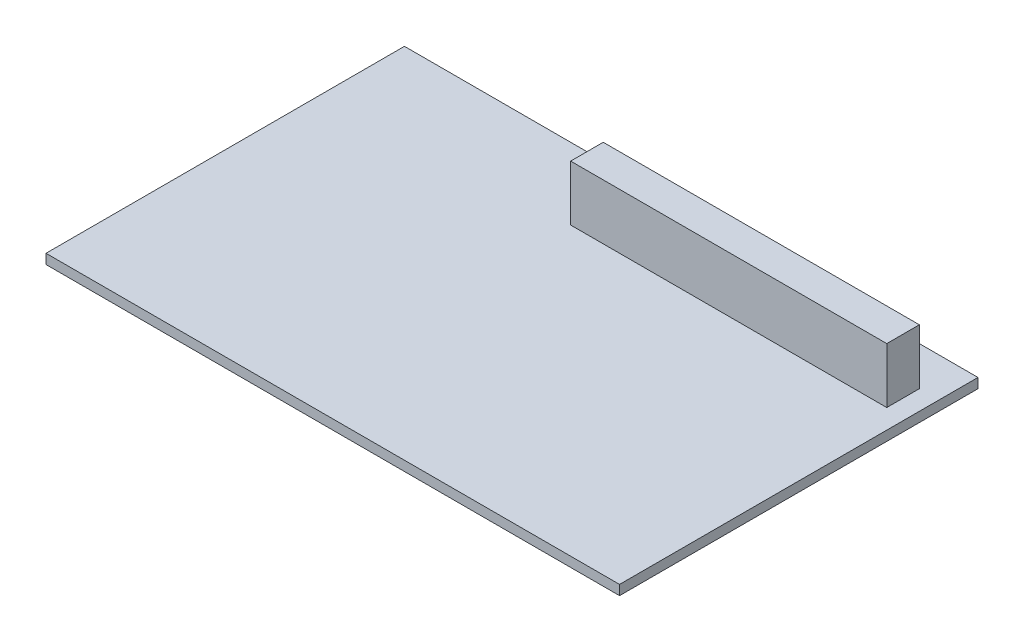
from build123d import *

# Parameters (mm, degrees)
SZKIC1_W                    = 88
SZKIC1_H                    = 55
DODANIE_WYCI_GNI_CIE1_DEPTH = 1.5
SZKIC2_W                    = 48.5
SZKIC2_H                    = 5
DODANIE_WYCI_GNI_CIE2_DEPTH = 8.5


with BuildPart() as part:
    # Szkic1 → Dodanie-wyciągnięcie1 (new body)
    with BuildSketch(Plane(origin=(0, 0, 0), x_dir=(1, 0, 0), z_dir=(0, 1, 0))):
        Rectangle(SZKIC1_W, SZKIC1_H)
    extrude(amount=DODANIE_WYCI_GNI_CIE1_DEPTH)

    # Szkic2 → Dodanie-wyciągnięcie2 (add)
    with BuildSketch(Plane(origin=(0, 1.5, 0), x_dir=(1, 0, 0), z_dir=(0, 1, 0))):
        with Locations((16.75, 19)):
            Rectangle(SZKIC2_W, SZKIC2_H)
    extrude(amount=DODANIE_WYCI_GNI_CIE2_DEPTH)


solid = part.part
